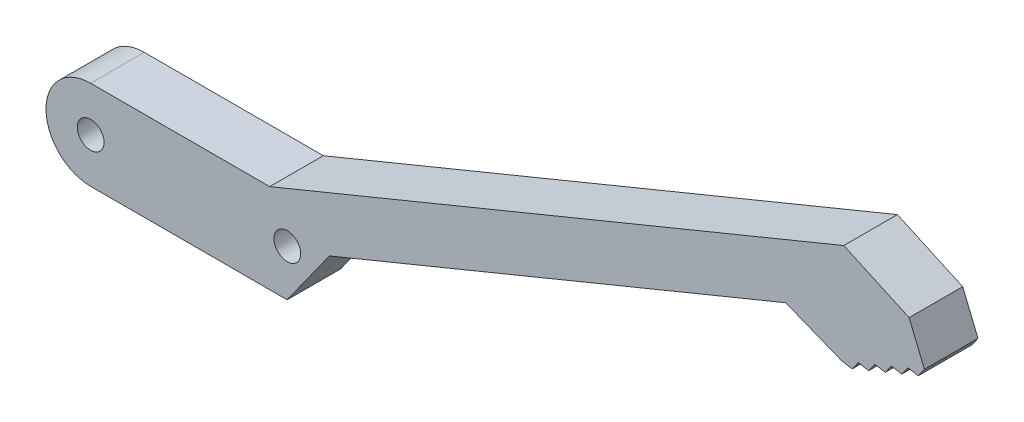
from build123d import *

# Parameters (mm, degrees)
SKETCH1_R           = 1.5
BOSS_EXTRUDE3_DEPTH = 6


with BuildPart() as part:
    # Sketch1 → Boss-Extrude3 (new body)
    with BuildSketch(Plane.XY):
        with BuildLine():
            Line((20.05, 5), (0, 5))
            ThreePointArc((0, 5), (-5, 0), (0, -5))
            Line((0, -5), (22, -5))
            Line((22, -5), (26.72989842, 1.621129525))
            Line((26.72989842, 1.621129525), (77.820171744, 22.626880444))
            Line((77.820171744, 22.626880444), (84.10849538, 20.130806965))
            Line((84.10849538, 20.130806965), (85.272939558, 19.928397094))
            Line((85.272939558, 19.928397094), (85.958251837, 20.89133379))
            Line((85.958251837, 20.89133379), (87.122696015, 20.688923919))
            Line((87.122696015, 20.688923919), (87.808008293, 21.651860615))
            Line((87.808008293, 21.651860615), (88.972452471, 21.449450744))
            Line((88.972452471, 21.449450744), (89.657764749, 22.412387441))
            Line((89.657764749, 22.412387441), (90.822208927, 22.20997757))
            Line((90.822208927, 22.20997757), (91.507521206, 23.172914266))
            Line((91.507521206, 23.172914266), (92.671965384, 22.970504395))
            Line((92.671965384, 22.970504395), (93.357277662, 23.933441092))
            Line((93.357277662, 23.933441092), (91.646092305, 28.095393119))
            Line((91.646092305, 28.095393119), (84.329036858, 31.428307185))
            Line((84.329036858, 31.428307185), (20.05, 5))
        make_face()
        Circle(SKETCH1_R, mode=Mode.SUBTRACT)
        with Locations((22.020705275, 0.206842568)):
            Circle(SKETCH1_R, mode=Mode.SUBTRACT)
    extrude(amount=BOSS_EXTRUDE3_DEPTH)


solid = part.part
